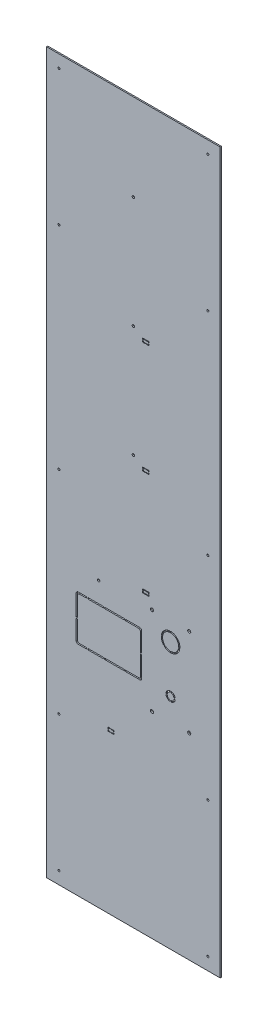
from build123d import *

# Parameters (mm, degrees)
BOSS_EXTRUDE2_DEPTH     = 2
SKETCH3_R               = 2
SKETCH3_R_2             = 1.65
SKETCH3_R_3             = 2.5
SKETCH3_W               = 25.058500374
SKETCH3_H               = 2
SKETCH3_W_2             = 31.89058371
CUT_EXTRUDE8_DEPTH      = 2
SKETCH4_W               = 3.627685546
SKETCH4_H               = 9.431982422
CUT_EXTRUDE2_DEPTH      = 0.1
CUT_EXTRUDE2_DEPTH_BACK = 2


with BuildPart() as part:
    # Sketch2 → Boss-Extrude2 (new body)
    with BuildSketch(Plane.XY):
        Polygon((-140, 680), (140, 680), (140, 580), (140, -480), (-140, -480), align=None)
    extrude(amount=BOSS_EXTRUDE2_DEPTH)

    # Sketch3 → Cut-Extrude8 (cut)
    with BuildSketch(Plane.XY):
        with Locations((0, 540)):
            Circle(SKETCH3_R)
        with Locations((-56.100012279, -23)):
            Circle(SKETCH3_R)
        with Locations((-120, -460)):
            Circle(SKETCH3_R_2)
        with Locations((120, -460)):
            Circle(SKETCH3_R_2)
        with Locations((90, -21)):
            Circle(SKETCH3_R_3)
        with Locations((89.999987721, -163)):
            Circle(SKETCH3_R_3)
        with Locations((29.999987721, -163)):
            Circle(SKETCH3_R_3)
        with Locations((29.999987721, -21)):
            Circle(SKETCH3_R_3)
        with Locations((-120, 660)):
            Circle(SKETCH3_R_2)
        with Locations((120, 660)):
            Circle(SKETCH3_R_2)
        with Locations((-120, 441.5)):
            Circle(SKETCH3_R_2)
        with Locations((120, 441.5)):
            Circle(SKETCH3_R_2)
        with Locations((120, -241.5)):
            Circle(SKETCH3_R_2)
        with Locations((-120, -241.5)):
            Circle(SKETCH3_R_2)
        with Locations((120, 100)):
            Circle(SKETCH3_R_2)
        with Locations((-120, 100)):
            Circle(SKETCH3_R_2)
        with Locations((0, 360)):
            Circle(SKETCH3_R)
        with Locations((0, 180)):
            Circle(SKETCH3_R)
        with Locations((-60.898913046, -127.55)):
            Rectangle(SKETCH3_W, SKETCH3_H)
        with BuildLine():
            Line((13.482340662, -92.055268464), (11.482340662, -92.055268464))
            Line((11.482340662, -92.055268464), (11.482340662, -123.55))
            ThreePointArc((11.482340662, -123.55), (10.603661005, -125.671320344), (8.482340662, -126.55))
            Line((8.482340662, -126.55), (-12.479079149, -126.55))
            Line((-12.479079149, -126.55), (-12.479079149, -128.55))
            Line((-12.479079149, -128.55), (10.482340662, -128.55))
            ThreePointArc((10.482340662, -128.55), (12.603661005, -127.671320344), (13.482340662, -125.55))
            Line((13.482340662, -125.55), (13.482340662, -92.055268464))
        make_face()
        with BuildLine():
            Line((60, -36), (60.00001461, -38.000005513))
            ThreePointArc((60.00001461, -38.000005513), (64.40229458, -38.768082792), (68.284375962, -40.981554223))
            Line((68.284375962, -40.981554223), (69.558885127, -39.44026342))
            ThreePointArc((69.558885127, -39.44026342), (65.079558828, -36.88624879), (60, -36))
        make_face()
        with BuildLine():
            Line((59.000556004, -36.033342163), (59.122400034, -38.029662698))
            ThreePointArc((59.122400034, -38.029662698), (54.411111276, -39.262707552), (50.484141952, -42.142907772))
            Line((50.484141952, -42.142907772), (49.02015594, -40.780271897))
            ThreePointArc((49.02015594, -40.780271897), (53.557238864, -37.45413019), (59.000556004, -36.033342163))
        make_face()
        with BuildLine():
            Line((74.933661101, -52.409179713), (72.94252229, -52.221291353))
            ThreePointArc((72.94252229, -52.221291353), (72.168738974, -46.425929265), (68.933492433, -41.555801733))
            Line((68.933492433, -41.555801733), (70.307864595, -40.102856625))
            ThreePointArc((70.307864595, -40.102856625), (74.040835155, -45.722230337), (74.933661101, -52.409179713))
        make_face()
        with BuildLine():
            Line((74.806582661, -53.401072383), (72.832387322, -53.080932568))
            ThreePointArc((72.832387322, -53.080932568), (71.39953375, -57.249087296), (68.656303527, -60.698909196))
            Line((68.656303527, -60.698909196), (69.988033372, -62.191040241))
            ThreePointArc((69.988033372, -62.191040241), (73.153293496, -58.210477998), (74.806582661, -53.401072383))
        make_face()
        with BuildLine():
            Line((60, -66.000017478), (60.00001461, -64.000008617))
            ThreePointArc((60.00001461, -64.000008617), (64.224735631, -63.294386783), (67.990832799, -61.254121606))
            Line((67.990832799, -61.254121606), (69.220183567, -62.831670149))
            ThreePointArc((69.220183567, -62.831670149), (64.874684241, -65.185832318), (60, -66.000017478))
        make_face()
        with BuildLine():
            Line((59.000541044, -65.96712681), (59.000541044, -63.961530623))
            ThreePointArc((59.000541044, -63.961530623), (54.566773379, -62.810169218), (50.807625358, -60.192396318))
            Line((50.807625358, -60.192396318), (49.393414477, -61.606607198))
            ThreePointArc((49.393414477, -61.606607198), (53.800950165, -64.659397705), (59.000541044, -65.96712681))
        make_face()
        with BuildLine():
            Line((60.980600924, -119.564383163), (60.71910407, -121.54721432))
            ThreePointArc((60.71910407, -121.54721432), (63.889075017, -123.110912704), (65.452773401, -126.280883651))
            Line((65.452773401, -126.280883651), (67.435604557, -126.019386797))
            ThreePointArc((67.435604557, -126.019386797), (65.30328858, -121.696699141), (60.980600924, -119.564383163))
        make_face()
        with BuildLine():
            Line((58.987382691, -119.568672322), (59.257410699, -121.550359703))
            ThreePointArc((59.257410699, -121.550359703), (56.102540613, -123.119290524), (54.54720204, -126.280883651))
            Line((54.54720204, -126.280883651), (52.564370884, -126.019386797))
            ThreePointArc((52.564370884, -126.019386797), (54.685287119, -121.708123441), (58.987382691, -119.568672322))
        make_face()
        with BuildLine():
            Line((67.435604557, -127.980613203), (65.452773401, -127.719116349))
            ThreePointArc((65.452773401, -127.719116349), (63.889075017, -130.889087296), (60.71910407, -132.45278568))
            Line((60.71910407, -132.45278568), (60.980600924, -134.435616836))
            ThreePointArc((60.980600924, -134.435616836), (65.303288579, -132.303300859), (67.435604557, -127.980613203))
        make_face()
        with BuildLine():
            Line((52.564370884, -127.980613203), (54.54720204, -127.719116349))
            ThreePointArc((54.54720204, -127.719116349), (56.102540613, -130.880709476), (59.257410699, -132.449640297))
            Line((59.257410699, -132.449640297), (58.987382691, -134.431327677))
            ThreePointArc((58.987382691, -134.431327677), (54.685287119, -132.291876559), (52.564370884, -127.980613203))
        make_face()
        with BuildLine():
            Line((45.263274159, -48.201990118), (47.228183224, -48.575061007))
            ThreePointArc((47.228183224, -48.575061007), (48.212106329, -45.518651513), (49.915143539, -42.796628748))
            Line((49.915143539, -42.796628748), (48.363618413, -41.534565259))
            ThreePointArc((48.363618413, -41.534565259), (46.398572229, -44.675361768), (45.263274159, -48.201990118))
        make_face()
        with BuildLine():
            Line((45.108152373, -49.201990118), (47.093744677, -49.441726999))
            ThreePointArc((47.093744677, -49.441726999), (47.511194531, -54.609634938), (49.915144959, -59.203387129))
            Line((49.915144959, -59.203387129), (48.363618413, -60.46545222))
            ThreePointArc((48.363618413, -60.46545222), (45.589825437, -55.164965615), (45.108152373, -49.201990118))
        make_face()
        Polygon((-32.100012279, -221.1), (-35.600012279, -221.1), (-35.600012279, -220.1), (-31.100012279, -220.1), (-31.100012279, -222.5), (-32.100012279, -222.5), align=None)
        Polygon((24, 349.9), (20.5, 349.9), (20.5, 350.9), (25, 350.9), (25, 348.5), (24, 348.5), align=None)
        with Locations((-30.424371004, -56.560536927)):
            Rectangle(SKETCH3_W_2, SKETCH3_H)
        with BuildLine():
            Line((-12.479079149, -55.560536927), (-12.479079149, -57.560536927))
            Line((-12.479079149, -57.560536927), (8.482340662, -57.560536927))
            ThreePointArc((8.482340662, -57.560536927), (10.603661005, -58.439216583), (11.482340662, -60.560536927))
            Line((11.482340662, -60.560536927), (11.482340662, -90.055268464))
            Line((11.482340662, -90.055268464), (13.482340662, -90.055268464))
            Line((13.482340662, -90.055268464), (13.482340662, -58.560536927))
            ThreePointArc((13.482340662, -58.560536927), (12.603661005, -56.439216583), (10.482340662, -55.560536927))
            Line((10.482340662, -55.560536927), (-12.479079149, -55.560536927))
        make_face()
        with BuildLine():
            Line((-92.129424044, -93.879663492), (-90.129424044, -93.879663492))
            Line((-90.129424044, -93.879663492), (-90.129424044, -123.55))
            ThreePointArc((-90.129424044, -123.55), (-89.250744388, -125.671320344), (-87.129424044, -126.55))
            Line((-87.129424044, -126.55), (-75.428163233, -126.55))
            Line((-75.428163233, -126.55), (-75.428163233, -128.55))
            Line((-75.428163233, -128.55), (-89.129424044, -128.55))
            ThreePointArc((-89.129424044, -128.55), (-91.250744388, -127.671320344), (-92.129424044, -125.55))
            Line((-92.129424044, -125.55), (-92.129424044, -93.879663492))
        make_face()
        with BuildLine():
            Line((-90.129424044, -91.879663492), (-92.129424044, -91.879663492))
            Line((-92.129424044, -91.879663492), (-92.129424044, -58.560536927))
            ThreePointArc((-92.129424044, -58.560536927), (-91.250744388, -56.439216583), (-89.129424044, -55.560536927))
            Line((-89.129424044, -55.560536927), (-75.905968286, -55.560536927))
            Line((-75.905968286, -55.560536927), (-75.905968286, -57.560536927))
            Line((-75.905968286, -57.560536927), (-87.129424044, -57.560536927))
            ThreePointArc((-87.129424044, -57.560536927), (-89.250744388, -58.439216583), (-90.129424044, -60.560536927))
            Line((-90.129424044, -60.560536927), (-90.129424044, -91.879663492))
        make_face()
        with Locations((-30.424371004, -127.55)):
            Rectangle(SKETCH3_W_2, SKETCH3_H)
        with Locations((-60.898913046, -56.560536927)):
            Rectangle(SKETCH3_W, SKETCH3_H)
        Polygon((25, 345.1), (20.5, 345.1), (20.5, 346.1), (24, 346.1), (24, 347.5), (25, 347.5), align=None)
        Polygon((15, 350.9), (15, 348.5), (16, 348.5), (16, 349.9), (19.5, 349.9), (19.5, 350.9), align=None)
        Polygon((24, 169.9), (24, 168.5), (25, 168.5), (25, 170.9), (20.5, 170.9), (20.5, 169.9), align=None)
        Polygon((25, 165.1), (20.5, 165.1), (20.5, 166.1), (24, 166.1), (24, 167.5), (25, 167.5), align=None)
        Polygon((15, 170.9), (15, 168.5), (16, 168.5), (16, 169.9), (19.5, 169.9), (19.5, 170.9), align=None)
        Polygon((-40.100012279, -221.1), (-40.100012279, -222.5), (-41.100012279, -222.5), (-41.100012279, -220.1), (-36.600012279, -220.1), (-36.600012279, -221.1), align=None)
        Polygon((24, -0.1), (20.5, -0.1), (20.5, 0.9), (25, 0.9), (25, -1.5), (24, -1.5), align=None)
        Polygon((25, -4.9), (20.5, -4.9), (20.5, -3.9), (24, -3.9), (24, -2.5), (25, -2.5), align=None)
        Polygon((15, 0.9), (15, -1.5), (16, -1.5), (16, -0.1), (19.5, -0.1), (19.5, 0.9), align=None)
        Polygon((19.5, 346.1), (16, 346.1), (16, 347.5), (15, 347.5), (15, 345.1), (19.5, 345.1), align=None)
        Polygon((19.5, 165.1), (15, 165.1), (15, 167.5), (16, 167.5), (16, 166.1), (19.5, 166.1), align=None)
        Polygon((-31.100012279, -225.9), (-35.600012279, -225.9), (-35.600012279, -224.9), (-32.100012279, -224.9), (-32.100012279, -223.5), (-31.100012279, -223.5), align=None)
        Polygon((19.5, -3.9), (19.5, -4.9), (15, -4.9), (15, -2.5), (16, -2.5), (16, -3.9), align=None)
        Polygon((-40.100012279, -223.5), (-40.100012279, -224.9), (-36.600012279, -224.9), (-36.600012279, -225.9), (-41.100012279, -225.9), (-41.100012279, -223.5), align=None)
    extrude(amount=CUT_EXTRUDE8_DEPTH, mode=Mode.SUBTRACT)

    # Sketch4 → Cut-Extrude2 (cut, two sides)
    with BuildSketch(Plane.XY) as cut_extrude2_sk:
        Polygon((-40.383518528, -434.832888989), (-36.755832981, -434.832888989), (-36.755832981, -438.460574536), (-29.984153293, -438.460574536), (-29.984153293, -434.832888989), (-26.356467746, -434.832888989), (-26.356467746, -444.264871411), (-29.984153293, -444.264871411), (-29.984153293, -440.153494458), (-36.755832981, -440.153494458), (-36.755832981, -444.264871411), (-40.383518528, -444.264871411), align=None)
        Polygon((-15.813506626, -434.832888989), (-12.108354877, -434.832888989), (-4.529893039, -444.264871411), (-8.416429065, -444.264871411), (-9.933632968, -442.330105786), (-17.990117954, -442.330105786), (-19.509211277, -444.264871411), (-23.393857883, -444.264871411), align=None)
        Polygon((-13.961875461, -437.362821774), (-16.661856006, -440.637185864), (-11.261894916, -440.637185864), align=None, mode=Mode.SUBTRACT)
        with BuildLine():
            Line((-1.809128879, -434.832888989), (2.629117657, -434.832888989))
            add(Edge.make_bspline(
                [(2.629117657, -434.832888989), (2.804835782, -434.833224142), (3.151242882, -434.833884856), (3.662024342, -434.839925006), (4.155858911, -434.848306647), (4.631299384, -434.864865298), (5.089921392, -434.880415594), (5.531407861, -434.903554421), (5.955829858, -434.930565087), (6.362917326, -434.957470857), (6.752662805, -434.992578464), (7.125785071, -435.028874584), (7.481363637, -435.073717493), (7.81916817, -435.11815842), (8.140025543, -435.166768883), (8.443219118, -435.222697726), (8.730512906, -435.277470036), (9.086361961, -435.36144247), (9.51000491, -435.475647121), (9.998191566, -435.631247348), (10.462292384, -435.810347506), (10.904966088, -436.005292062), (11.323748721, -436.223465821), (11.718989575, -436.461094157), (12.090461167, -436.71974556), (12.439207596, -436.992807104), (12.755791309, -437.282924633), (13.032198802, -437.588708333), (13.266215545, -437.906603109), (13.45713007, -438.238012731), (13.605582702, -438.581699895), (13.711461958, -438.937404774), (13.778883348, -439.305110257), (13.78621373, -439.554886644), (13.789918972, -439.681139569)],
                knots=[0, 0, 0, 0, 0.000527151, 0.001039216, 0.001532444, 0.002008818, 0.002466374, 0.002909079, 0.00333502, 0.003742233, 0.004132937, 0.004508945, 0.004866805, 0.005208037, 0.005531106, 0.005840198, 0.00613293, 0.006408377, 0.006936837, 0.007448912, 0.007944721, 0.008428546, 0.008899258, 0.009360357, 0.009811102, 0.010256384, 0.010688268, 0.011097649, 0.011491052, 0.011870238, 0.012242626, 0.01261145, 0.012981723, 0.013360179, 0.013360179, 0.013360179, 0.013360179], degree=3))
            add(Edge.make_bspline(
                [(13.789918972, -439.681139569), (13.787992948, -439.771337995), (13.784179026, -439.94994931), (13.745876966, -440.214686867), (13.688456157, -440.474365413), (13.603983973, -440.728095328), (13.498403893, -440.977134961), (13.366090787, -441.219323753), (13.213891709, -441.458157676), (13.035148755, -441.688044785), (12.836282253, -441.910185374), (12.621653866, -442.125899446), (12.387782031, -442.3306147), (12.135867891, -442.525313475), (11.865994091, -442.710382004), (11.576805608, -442.884045721), (11.271746038, -443.050651113), (10.838205946, -443.256783496), (10.271362653, -443.488180708), (9.563179637, -443.721240739), (8.826840671, -443.906053811), (8.256878771, -444.008479048), (7.860567388, -444.064161877), (7.640180736, -444.090950805), (7.401203504, -444.112317985), (7.144982723, -444.135695326), (6.870966585, -444.156139106), (6.57998032, -444.174969606), (6.271366729, -444.192132703), (5.944423195, -444.206361503), (5.599383657, -444.222758176), (5.23654035, -444.233047527), (4.856143792, -444.242957973), (4.458071753, -444.249486366), (4.042437782, -444.258620139), (3.609091703, -444.260596394), (3.158165964, -444.266006919), (2.851441235, -444.265254544), (2.695247342, -444.264871411)],
                knots=[0, 0, 0, 0, 0.000270425, 0.000535496, 0.000800891, 0.001067373, 0.001336554, 0.0016113, 0.001894316, 0.002185311, 0.00248375, 0.002788363, 0.003097633, 0.003415472, 0.003743018, 0.004078718, 0.004427049, 0.004785366, 0.00551833, 0.006262207, 0.007020156, 0.007793984, 0.007998128, 0.008220768, 0.008459912, 0.008717871, 0.008992624, 0.009284207, 0.009592652, 0.009919871, 0.010265965, 0.010628911, 0.011008801, 0.01140754, 0.011823281, 0.012255975, 0.012707562, 0.013176138, 0.013176138, 0.013176138, 0.013176138], degree=3))
            Line((2.695247342, -444.264871411), (-1.809128879, -444.264871411))
            Line((-1.809128879, -444.264871411), (-1.809128879, -434.832888989))
        make_face()
        with BuildLine():
            Line((1.818556668, -436.525808911), (1.818556668, -442.571951489))
            Line((1.818556668, -442.571951489), (3.611615826, -442.571951489))
            add(Edge.make_bspline(
                [(3.611615826, -442.571951489), (3.824506975, -442.571742383), (4.235233457, -442.571338958), (4.828479203, -442.553805301), (5.377340595, -442.535962428), (5.8798998, -442.502519076), (6.337701536, -442.465312099), (6.748720253, -442.41253569), (7.11641956, -442.359123409), (7.442680222, -442.289291602), (7.740392954, -442.210639972), (8.019012349, -442.120010792), (8.284669833, -442.018828847), (8.534902892, -441.902049485), (8.772833797, -441.776590898), (8.997156655, -441.638031805), (9.207480023, -441.486569161), (9.402799211, -441.323255648), (9.581831568, -441.150131395), (9.736655261, -440.964987704), (9.868711193, -440.770254004), (9.977722013, -440.56630704), (10.057944575, -440.35015871), (10.119828033, -440.126107484), (10.156173176, -439.891424202), (10.160199089, -439.731646304), (10.162233426, -439.650908856)],
                knots=[0, 0, 0, 0, 0.000638635, 0.001232105, 0.001780431, 0.002285927, 0.002743003, 0.003158044, 0.003528948, 0.003857272, 0.004158378, 0.004452352, 0.004735865, 0.005010612, 0.005280243, 0.00554241, 0.005800929, 0.006057118, 0.006305633, 0.006547065, 0.00677974, 0.007010473, 0.007238913, 0.007469918, 0.00770694, 0.007949051, 0.007949051, 0.007949051, 0.007949051], degree=3))
            add(Edge.make_bspline(
                [(10.162233426, -439.650908856), (10.160670593, -439.58787402), (10.157598829, -439.463978455), (10.136541283, -439.280614298), (10.100498142, -439.103168936), (10.050789278, -438.930247368), (9.989510596, -438.761997528), (9.91060271, -438.599975151), (9.817921328, -438.443595055), (9.712475901, -438.292054063), (9.590991149, -438.147439191), (9.458297641, -438.005526764), (9.307842688, -437.871891424), (9.144494479, -437.743414305), (8.968743779, -437.617881361), (8.777566814, -437.499780194), (8.573105962, -437.385332715), (8.429414239, -437.31667809), (8.35594833, -437.281576733)],
                knots=[0, 0, 0, 0, 0.000189093, 0.000371664, 0.000552861, 0.000731679, 0.000911024, 0.001089332, 0.001271443, 0.001455949, 0.001642467, 0.001837599, 0.002038287, 0.002245435, 0.002460903, 0.002685816, 0.002919249, 0.003163452, 0.003163452, 0.003163452, 0.003163452], degree=3))
            add(Edge.make_bspline(
                [(8.35594833, -437.281576733), (8.285628916, -437.250827599), (8.141145407, -437.187648136), (7.914655485, -437.100572517), (7.672111526, -437.021938321), (7.414983635, -436.948239704), (7.142091568, -436.880341092), (6.854248418, -436.817889816), (6.55013649, -436.76425395), (6.231749908, -436.711947621), (5.89681555, -436.670365862), (5.546895955, -436.629070987), (5.181325477, -436.59832722), (4.800273686, -436.571463628), (4.40404583, -436.551172894), (3.992134186, -436.535384396), (3.565028917, -436.528966621), (3.275299712, -436.526873573), (3.12792442, -436.525808911)],
                knots=[0, 0, 0, 0, 0.00023023, 0.000473048, 0.00072758, 0.000994898, 0.001275348, 0.001571077, 0.00187831, 0.002201671, 0.00253891, 0.002890697, 0.003258649, 0.003639343, 0.004036665, 0.004448836, 0.004875911, 0.005318052, 0.005318052, 0.005318052, 0.005318052], degree=3))
            Line((3.12792442, -436.525808911), (1.818556668, -436.525808911))
        make_face(mode=Mode.SUBTRACT)
        with Locations((18.626833035, -439.5488802)):
            Rectangle(SKETCH4_W, SKETCH4_H)
        with BuildLine():
            Line((25.156667019, -434.832888989), (29.143342282, -434.832888989))
            add(Edge.make_bspline(
                [(29.143342282, -434.832888989), (29.277490255, -434.833603463), (29.540747892, -434.835005575), (29.928103542, -434.835629292), (30.300314549, -434.842055064), (30.658056513, -434.849329172), (31.000669065, -434.858983178), (31.328880708, -434.869341575), (31.642403067, -434.886010578), (31.941732353, -434.899386972), (32.225713423, -434.919114865), (32.494666353, -434.939708502), (32.749141269, -434.962246593), (32.98913399, -434.986684951), (33.214631062, -435.013167197), (33.425049676, -435.041235191), (33.621180646, -435.070938501), (33.859441792, -435.116479413), (34.14129159, -435.177198051), (34.463686243, -435.261536978), (34.768881689, -435.358072202), (35.056674515, -435.46547595), (35.327759934, -435.585043995), (35.582778763, -435.714299989), (35.819910829, -435.856738739), (36.038857676, -436.008895113), (36.236392008, -436.17014184), (36.411000527, -436.338586845), (36.55650068, -436.516755838), (36.677477439, -436.701135875), (36.77112411, -436.893480666), (36.83723094, -437.092973922), (36.87897337, -437.299999557), (36.883757389, -437.440719373), (36.886183621, -437.512085919)],
                knots=[0, 0, 0, 0, 0.000402451, 0.000789786, 0.001162045, 0.001519225, 0.00186323, 0.002190296, 0.002504303, 0.002805101, 0.003089143, 0.003358245, 0.003614322, 0.003855532, 0.004081924, 0.004295428, 0.004492372, 0.004676917, 0.005023058, 0.005357149, 0.005676242, 0.005982963, 0.006278209, 0.006564666, 0.006840094, 0.007107412, 0.007363852, 0.00760435, 0.007833936, 0.008052473, 0.008264576, 0.008473697, 0.008681576, 0.00889549, 0.00889549, 0.00889549, 0.00889549], degree=3))
            add(Edge.make_bspline(
                [(36.886183621, -437.512085919), (36.883244315, -437.586626862), (36.877439114, -437.733847022), (36.832184016, -437.949323181), (36.760480301, -438.155842877), (36.656303323, -438.352478877), (36.523535282, -438.539204071), (36.362008321, -438.716806929), (36.172672804, -438.885576617), (35.950882558, -439.041057972), (35.703291851, -439.191754345), (35.423579441, -439.327504364), (35.117403557, -439.459329443), (34.779372733, -439.576494318), (34.413364254, -439.688117378), (34.017355658, -439.7896312), (33.592570629, -439.882269764), (33.298376574, -439.934105626), (33.14702232, -439.960773663)],
                knots=[0, 0, 0, 0, 0.000223463, 0.000441345, 0.000657665, 0.000877399, 0.001106487, 0.001343268, 0.001596204, 0.001865703, 0.002154741, 0.002464847, 0.002797541, 0.003154301, 0.003537425, 0.003945281, 0.004380365, 0.004841383, 0.004841383, 0.004841383, 0.004841383], degree=3))
            Line((33.14702232, -439.960773663), (37.793105008, -444.264871411))
            Line((37.793105008, -444.264871411), (33.708179928, -444.264871411))
            Line((33.708179928, -444.264871411), (29.269933392, -440.153494458))
            Line((29.269933392, -440.153494458), (28.784352566, -440.153494458))
            Line((28.784352566, -440.153494458), (28.784352566, -444.264871411))
            Line((28.784352566, -444.264871411), (25.156667019, -444.264871411))
            Line((25.156667019, -444.264871411), (25.156667019, -434.832888989))
        make_face()
        with BuildLine():
            Line((28.784352566, -438.460574536), (30.00302818, -438.460574536))
            add(Edge.make_bspline(
                [(30.00302818, -438.460574536), (30.151663708, -438.45965686), (30.436999711, -438.457895196), (30.84717395, -438.449928065), (31.221316171, -438.430334431), (31.558978786, -438.406111101), (31.861208791, -438.377633466), (32.12640913, -438.337588677), (32.356510446, -438.293874836), (32.552334491, -438.240665647), (32.71959499, -438.180160909), (32.862935195, -438.110877583), (32.983685281, -438.030094489), (33.0856929, -437.942760549), (33.162769263, -437.841736644), (33.218629993, -437.733187453), (33.25214475, -437.614166177), (33.25633809, -437.531826134), (33.258498074, -437.489412884)],
                knots=[0, 0, 0, 0, 0.000445919, 0.000856032, 0.001230614, 0.001569711, 0.001871646, 0.002140992, 0.002374066, 0.002573916, 0.002749062, 0.002907075, 0.003050135, 0.003183977, 0.003307933, 0.003428767, 0.003548413, 0.003675511, 0.003675511, 0.003675511, 0.003675511], degree=3))
            add(Edge.make_bspline(
                [(33.258498074, -437.489412884), (33.254788828, -437.438872447), (33.247272795, -437.33646252), (33.174219146, -437.192821389), (33.062231054, -437.060886476), (32.907255281, -436.9451354), (32.719606843, -436.840019331), (32.500779094, -436.749542571), (32.252299062, -436.677230519), (32.022788661, -436.630054317), (31.812787623, -436.601274819), (31.621948478, -436.580268255), (31.401301626, -436.5645395), (31.15005771, -436.548666388), (30.868448271, -436.538086852), (30.556037536, -436.530482856), (30.214019123, -436.527332356), (29.975946592, -436.526330849), (29.851874615, -436.525808911)],
                knots=[0, 0, 0, 0, 0.000150704, 0.000305371, 0.000473019, 0.000666904, 0.000881808, 0.001117259, 0.001375509, 0.001657127, 0.001819321, 0.00201128, 0.002232995, 0.002482856, 0.002766496, 0.003078342, 0.003420348, 0.003792568, 0.003792568, 0.003792568, 0.003792568], degree=3))
            Line((29.851874615, -436.525808911), (28.784352566, -436.525808911))
            Line((28.784352566, -436.525808911), (28.784352566, -438.460574536))
        make_face(mode=Mode.SUBTRACT)
    extrude(amount=CUT_EXTRUDE2_DEPTH, mode=Mode.SUBTRACT)
    extrude(cut_extrude2_sk.sketch, amount=-CUT_EXTRUDE2_DEPTH_BACK, mode=Mode.SUBTRACT)


solid = part.part
